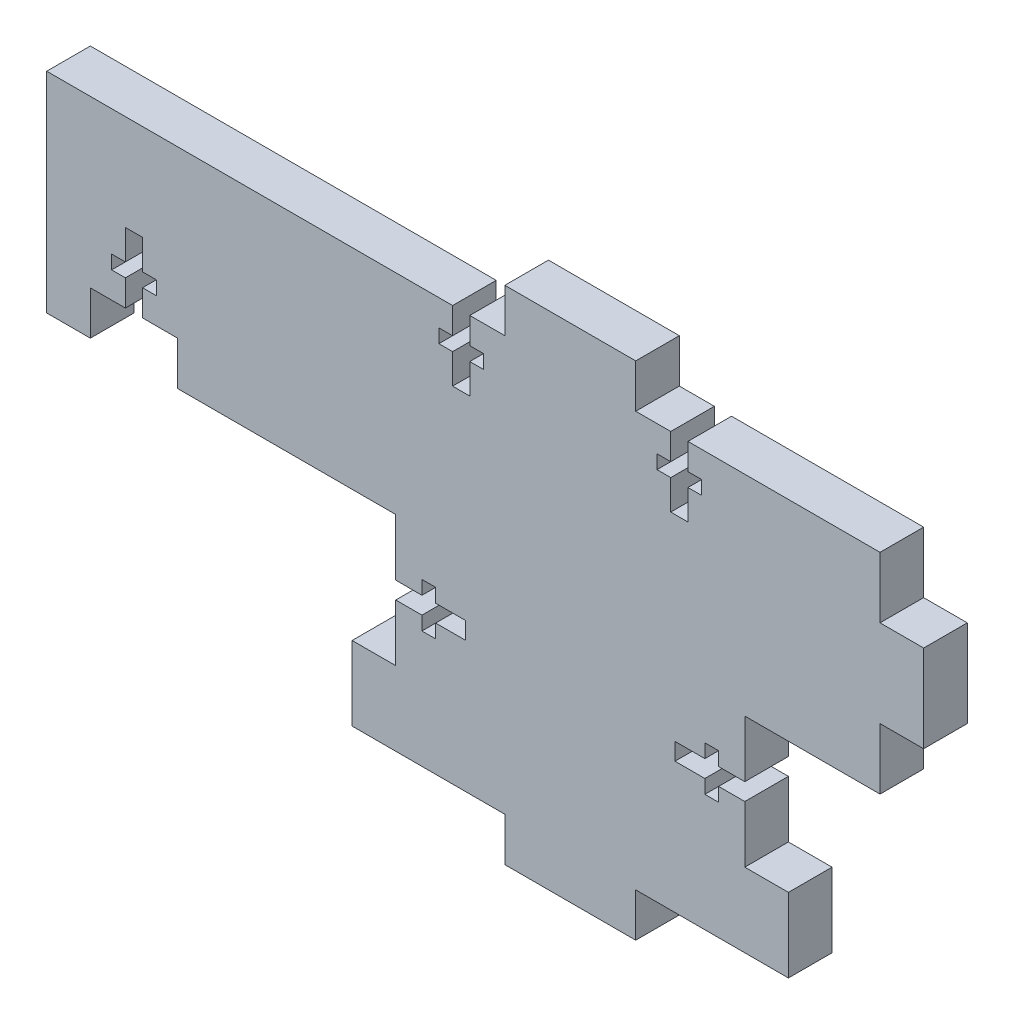
from build123d import *

# Parameters (mm, degrees)
BOSS_EXTRUDE1_DEPTH = 6.35
SKETCH2_W           = 12.7
SKETCH2_H           = 6.35
CUT_EXTRUDE1_DEPTH  = 7.35
CUT_EXTRUDE2_DEPTH  = 7.35
CUT_EXTRUDE3_DEPTH  = 7.35


with BuildPart() as part:
    # Sketch1 → Boss-Extrude1 (new body)
    with BuildSketch(Plane.XY):
        Polygon((0, -6.35), (19.05, -6.35), (19.05, 0), (34.925, 0), (41.275, 0), (41.275, 10.795), (34.925, 10.795), (34.925, 29.845), (54.61, 29.845), (54.61, 38.735), (60.96, 38.735), (60.96, 51.435), (54.61, 51.435), (54.61, 60.325), (34.925, 60.325), (19.05, 60.325), (19.05, 66.675), (0, 66.675), (0, 60.325), (-15.875, 60.325), (-66.675, 60.325), (-66.675, 29.845), (-15.875, 29.845), (-15.875, 10.795), (-22.225, 10.795), (-22.225, 0), (-15.875, 0), (0, 0), align=None)
    extrude(amount=BOSS_EXTRUDE1_DEPTH)

    # Sketch2 → Cut-Extrude1 (cut, through all)
    with BuildSketch(Plane.XY.offset(6.35)):
        with Locations((-53.975, 33.02)):
            Rectangle(SKETCH2_W, SKETCH2_H)
    extrude(amount=-CUT_EXTRUDE1_DEPTH, mode=Mode.SUBTRACT)

    # Sketch3 → Cut-Extrude2 (cut, through all)
    with BuildSketch(Plane.XY.offset(6.35)):
        Polygon((-15.875, 21.57), (-15.875, 19.07), (-12.065, 19.07), (-12.065, 17.07), (-10.065, 17.07), (-10.065, 19.07), (-5.715, 19.07), (-5.715, 21.57), (-10.065, 21.57), (-10.065, 23.57), (-12.065, 23.57), (-12.065, 21.57), align=None)
        Polygon((34.925, 21.57), (34.925, 19.07), (31.115, 19.07), (31.115, 17.07), (29.115, 17.07), (29.115, 19.07), (24.765, 19.07), (24.765, 21.57), (29.115, 21.57), (29.115, 23.57), (31.115, 23.57), (31.115, 21.57), align=None)
    extrude(amount=-CUT_EXTRUDE2_DEPTH, mode=Mode.SUBTRACT)

    # Sketch5 → Cut-Extrude3 (cut, through all)
    with BuildSketch(Plane.XY.offset(6.35)):
        Polygon((-3.1, 56.515), (-3.1, 54.515), (-5.1, 54.515), (-5.1, 50.165), (-7.6, 50.165), (-7.6, 54.515), (-9.6, 54.515), (-9.6, 56.515), (-7.6, 56.515), (-7.6, 60.325), (-5.1, 60.325), (-5.1, 56.515), align=None)
        Polygon((26.65, 60.325), (26.65, 56.515), (28.65, 56.515), (28.65, 54.515), (26.65, 54.515), (26.65, 50.165), (24.15, 50.165), (24.15, 54.515), (22.15, 54.515), (22.15, 56.515), (24.15, 56.515), (24.15, 60.325), align=None)
        Polygon((-52.725, 42.005), (-50.725, 42.005), (-50.725, 40.005), (-52.725, 40.005), (-52.725, 36.195), (-55.225, 36.195), (-55.225, 40.005), (-57.225, 40.005), (-57.225, 42.005), (-55.225, 42.005), (-55.225, 46.355), (-52.725, 46.355), align=None)
    extrude(amount=-CUT_EXTRUDE3_DEPTH, mode=Mode.SUBTRACT)


solid = part.part
